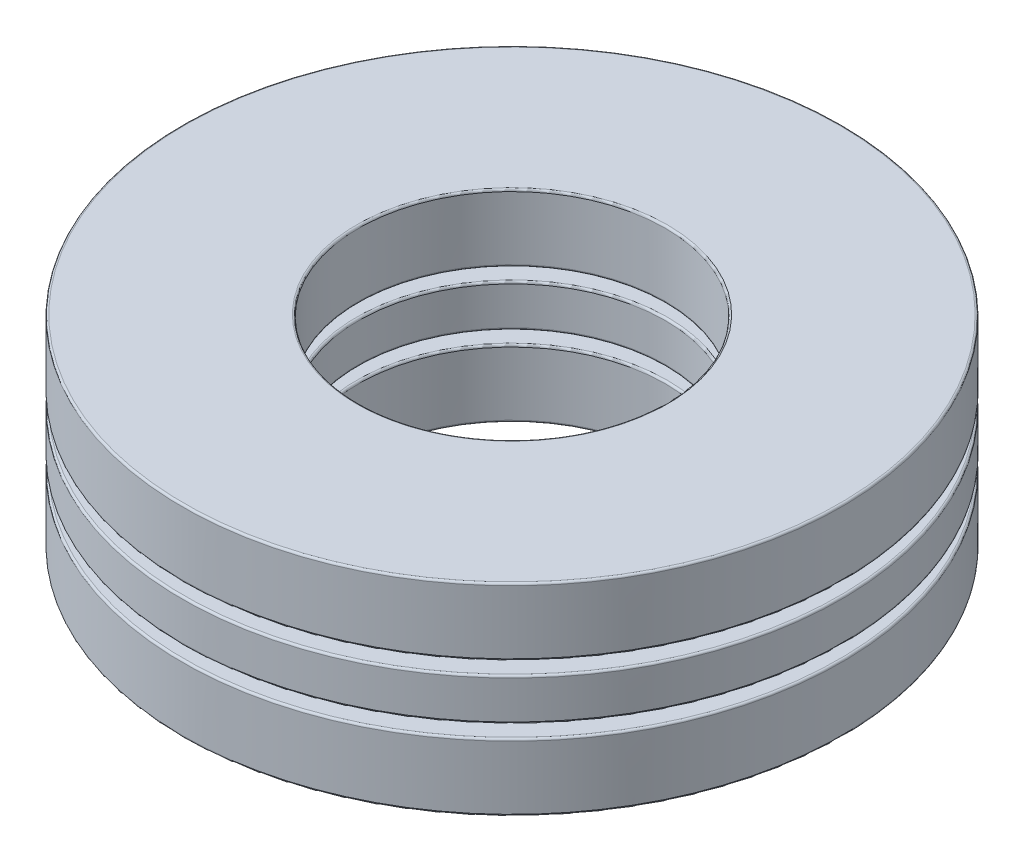
from build123d import *

# Parameters (mm, degrees)
SKETCH1_W         = 5.51815
SKETCH1_H         = 1.317625
CIRPATTERN1_COUNT = 4
CIRPATTERN1_ANGLE = 270
CIRPATTERN2_COUNT = 4
SKETCH4_W         = 5.51815
SKETCH4_H         = 2.1082
FILLET1_R         = 0.063246
FILLET2_R         = 0.063246
FILLET3_R         = 0.063246


with BuildPart() as part:
    # Sketch1 → Revolve1 (revolve)
    with BuildSketch(Plane(origin=(0, 0, 0), x_dir=(0, 0, -1), z_dir=(1, 0, 0))):
        with Locations((-7.559675, 0)):
            Rectangle(SKETCH1_W, SKETCH1_H)
    revolve(axis=Axis((0, -3.1623, 0), (0, 1, 0)))

    # Sketch3 → Cut-Revolve1 (revolve, cut)
    with BuildSketch(Plane(origin=(0, 0, 0), x_dir=(0, 0, -1), z_dir=(1, 0, 0))):
        with BuildLine():
            Line((-7.559675, 1.0541), (-7.559675, -1.0541))
            ThreePointArc((-7.559675, -1.0541), (-8.613775, 0), (-7.559675, 1.0541))
        make_face()
    cut_revolve1 = revolve(axis=Axis((0, 1.0541, 7.559675), (0, -1, 0)), mode=Mode.SUBTRACT)

    # CirPattern2: Cut-Revolve1 ×4 about axis
    cirpattern2_axis = Axis((0, 0, 0), (0, 1, 0))
    for i in range(1, CIRPATTERN2_COUNT):
        add(cut_revolve1.rotate(cirpattern2_axis, i * 360 / CIRPATTERN2_COUNT), mode=Mode.SUBTRACT)

    # Fillet2
    fillet2_edges = [part.edges().sort_by_distance(p)[0] for p in [
        (0, 0.6588125, -10.31875),
        (0, 0.6588125, -4.8006),
        (0, -0.6588125, -4.8006),
        (0, -0.6588125, -10.31875),
    ]]
    fillet(fillet2_edges, radius=FILLET2_R)


with BuildPart() as body_2:
    # Sketch2 → Revolve2 (revolve)
    with BuildSketch(Plane(origin=(0, 0, 0), x_dir=(0, 0, -1), z_dir=(1, 0, 0))):
        with BuildLine():
            Line((-7.559675, 1.0541), (-7.559675, -1.0541))
            ThreePointArc((-7.559675, -1.0541), (-8.613775, 0), (-7.559675, 1.0541))
        make_face()
    revolve(axis=Axis((0, 1.0541, 7.559675), (0, -1, 0)))


with BuildPart() as cirpattern1_1:
    # CirPattern1: pattern copy
    add(body_2.part.rotate(Axis((0, 3.1623, 0), (0, -1, 0)), 1 * CIRPATTERN1_ANGLE / (CIRPATTERN1_COUNT - 1)))


with BuildPart() as cirpattern1_2:
    # CirPattern1: pattern copy
    add(body_2.part.rotate(Axis((0, 3.1623, 0), (0, -1, 0)), 2 * CIRPATTERN1_ANGLE / (CIRPATTERN1_COUNT - 1)))


with BuildPart() as cirpattern1_3:
    # CirPattern1: pattern copy
    add(body_2.part.rotate(Axis((0, 3.1623, 0), (0, -1, 0)), 3 * CIRPATTERN1_ANGLE / (CIRPATTERN1_COUNT - 1)))


with BuildPart() as body_6:
    # Sketch4 → Revolve3 (revolve)
    with BuildSketch(Plane(origin=(0, 0, 0), x_dir=(0, 0, -1), z_dir=(1, 0, 0))):
        with Locations((-7.559675, 2.1082)):
            Rectangle(SKETCH4_W, SKETCH4_H)
        with Locations((-7.559675, -2.1082)):
            Rectangle(SKETCH4_W, SKETCH4_H)
    revolve(axis=Axis((0, -3.1623, 0), (0, 1, 0)))

    # Fillet1
    fillet1_edges = [body_6.edges().sort_by_distance(p)[0] for p in [
        (0, 1.0541, -10.31875),
        (0, 1.0541, -4.8006),
        (0, 3.1623, -4.8006),
        (0, 3.1623, -10.31875),
    ]]
    fillet(fillet1_edges, radius=FILLET1_R)

    # Fillet3
    fillet3_edges = [body_6.edges().sort_by_distance(p)[0] for p in [
        (0, -3.1623, -10.31875),
        (0, -3.1623, -4.8006),
        (0, -1.0541, -4.8006),
        (0, -1.0541, -10.31875),
    ]]
    fillet(fillet3_edges, radius=FILLET3_R)


solid = Compound([part.part, body_2.part, cirpattern1_1.part, cirpattern1_2.part, cirpattern1_3.part, body_6.part])
